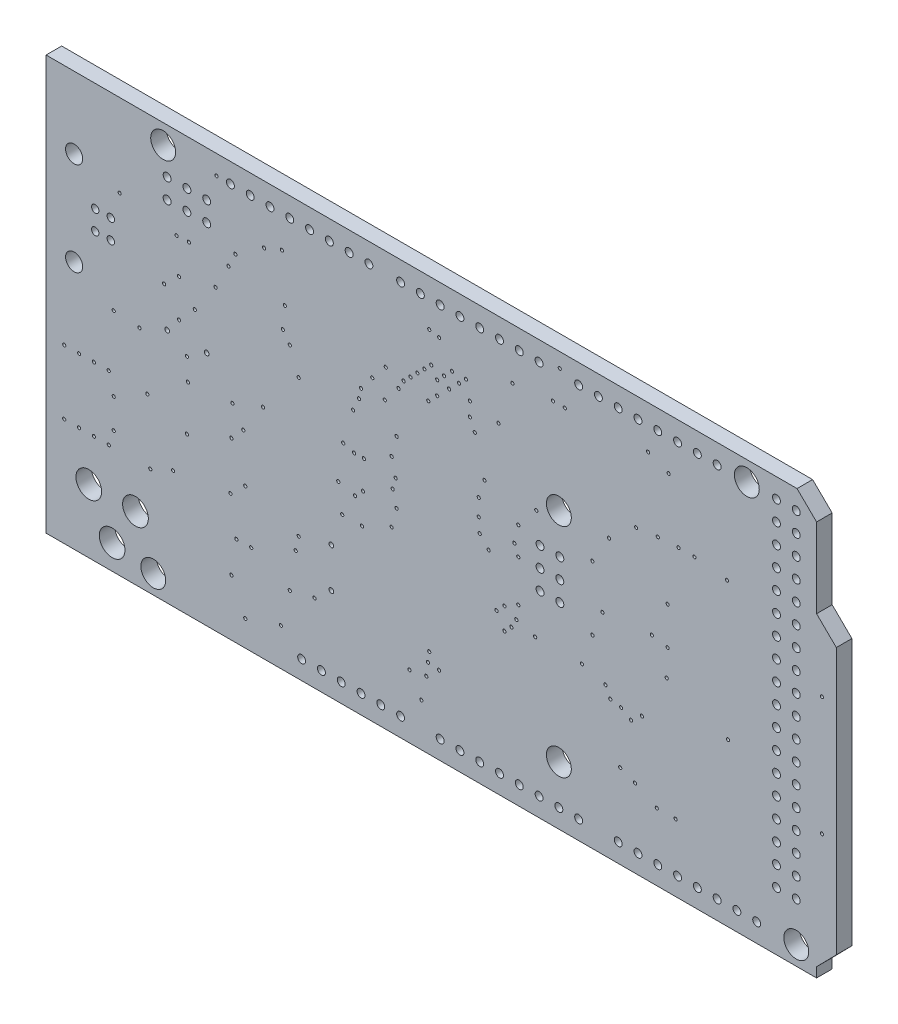
from build123d import *

# Parameters (mm, degrees)
SKETCH1_W           = 134.5210924
SKETCH1_H           = 72.181339
SKETCH1_R           = 1.5999968
SKETCH1_R_2         = 0.508
SKETCH1_R_3         = 0.3048
SKETCH1_R_4         = 1.651
SKETCH1_R_5         = 0.4750054
SKETCH1_R_6         = 1.0999978
SKETCH1_R_7         = 0.2032
BOSS_EXTRUDE1_DEPTH = 2
SKETCH2_W           = 162.13268737
SKETCH2_H           = 90.144306229
CUT_EXTRUDE1_DEPTH  = 10


with BuildPart() as part:
    # Sketch1 → Boss-Extrude1 (new body)
    with BuildSketch(Plane(origin=(0, 0, 0), x_dir=(-1, 0, 0), z_dir=(0, 0, -1))):
        with Locations((-40.0783056, -28.4573305)):
            Rectangle(SKETCH1_W, SKETCH1_H)
        with Locations((-81.88, -46.26)):
            Circle(SKETCH1_R, mode=Mode.SUBTRACT)
        with Locations((-0.6, 2)):
            Circle(SKETCH1_R, mode=Mode.SUBTRACT)
        with Locations((-75.53, 2)):
            Circle(SKETCH1_R, mode=Mode.SUBTRACT)
        with Locations((0.67, -46.26)):
            Circle(SKETCH1_R, mode=Mode.SUBTRACT)
        with Locations((-51.4, -13.24)):
            Circle(SKETCH1_R, mode=Mode.SUBTRACT)
        with Locations((-51.4, -41.18)):
            Circle(SKETCH1_R, mode=Mode.SUBTRACT)
        with Locations((-59.02, -46.26)):
            Circle(SKETCH1_R_2, mode=Mode.SUBTRACT)
        with Locations((-61.56, -46.26)):
            Circle(SKETCH1_R_2, mode=Mode.SUBTRACT)
        with Locations((-64.1, -46.26)):
            Circle(SKETCH1_R_2, mode=Mode.SUBTRACT)
        with Locations((-66.64, -46.26)):
            Circle(SKETCH1_R_2, mode=Mode.SUBTRACT)
        with Locations((-69.18, -46.26)):
            Circle(SKETCH1_R_2, mode=Mode.SUBTRACT)
        with Locations((-71.72, -46.26)):
            Circle(SKETCH1_R_2, mode=Mode.SUBTRACT)
        with Locations((-74.26, -46.26)):
            Circle(SKETCH1_R_2, mode=Mode.SUBTRACT)
        with Locations((-76.8, -46.26)):
            Circle(SKETCH1_R_2, mode=Mode.SUBTRACT)
        with Locations((-36.16, -46.26)):
            Circle(SKETCH1_R_2, mode=Mode.SUBTRACT)
        with Locations((-38.7, -46.26)):
            Circle(SKETCH1_R_2, mode=Mode.SUBTRACT)
        with Locations((-41.24, -46.26)):
            Circle(SKETCH1_R_2, mode=Mode.SUBTRACT)
        with Locations((-43.78, -46.26)):
            Circle(SKETCH1_R_2, mode=Mode.SUBTRACT)
        with Locations((-46.32, -46.26)):
            Circle(SKETCH1_R_2, mode=Mode.SUBTRACT)
        with Locations((-48.86, -46.26)):
            Circle(SKETCH1_R_2, mode=Mode.SUBTRACT)
        with Locations((-51.4, -46.26)):
            Circle(SKETCH1_R_2, mode=Mode.SUBTRACT)
        with Locations((-53.94, -46.26)):
            Circle(SKETCH1_R_2, mode=Mode.SUBTRACT)
        with Locations((-71.72, 2)):
            Circle(SKETCH1_R_2, mode=Mode.SUBTRACT)
        with Locations((-69.18, 2)):
            Circle(SKETCH1_R_2, mode=Mode.SUBTRACT)
        with Locations((-66.64, 2)):
            Circle(SKETCH1_R_2, mode=Mode.SUBTRACT)
        with Locations((-64.1, 2)):
            Circle(SKETCH1_R_2, mode=Mode.SUBTRACT)
        with Locations((-61.56, 2)):
            Circle(SKETCH1_R_2, mode=Mode.SUBTRACT)
        with Locations((-59.02, 2)):
            Circle(SKETCH1_R_2, mode=Mode.SUBTRACT)
        with Locations((-56.48, 2)):
            Circle(SKETCH1_R_2, mode=Mode.SUBTRACT)
        with Locations((-53.94, 2)):
            Circle(SKETCH1_R_2, mode=Mode.SUBTRACT)
        with Locations((-48.987, -18.32)):
            Circle(SKETCH1_R_2, mode=Mode.SUBTRACT)
        with Locations((-51.527, -18.32)):
            Circle(SKETCH1_R_2, mode=Mode.SUBTRACT)
        with Locations((-48.987, -20.86)):
            Circle(SKETCH1_R_2, mode=Mode.SUBTRACT)
        with Locations((-51.527, -20.86)):
            Circle(SKETCH1_R_2, mode=Mode.SUBTRACT)
        with Locations((-48.987, -23.4)):
            Circle(SKETCH1_R_2, mode=Mode.SUBTRACT)
        with Locations((-51.527, -23.4)):
            Circle(SKETCH1_R_2, mode=Mode.SUBTRACT)
        with Locations((-6.188, -1.302)):
            Circle(SKETCH1_R_2, mode=Mode.SUBTRACT)
        with Locations((-6.188, -3.842)):
            Circle(SKETCH1_R_2, mode=Mode.SUBTRACT)
        with Locations((-3.648, -1.302)):
            Circle(SKETCH1_R_2, mode=Mode.SUBTRACT)
        with Locations((-3.648, -3.842)):
            Circle(SKETCH1_R_2, mode=Mode.SUBTRACT)
        with Locations((-1.108, -1.302)):
            Circle(SKETCH1_R_2, mode=Mode.SUBTRACT)
        with Locations((-1.108, -3.842)):
            Circle(SKETCH1_R_2, mode=Mode.SUBTRACT)
        with Locations((-79.34, 2)):
            Circle(SKETCH1_R_2, mode=Mode.SUBTRACT)
        with Locations((-81.88, 2)):
            Circle(SKETCH1_R_2, mode=Mode.SUBTRACT)
        with Locations((-79.34, -41.18)):
            Circle(SKETCH1_R_2, mode=Mode.SUBTRACT)
        with Locations((-81.88, -41.18)):
            Circle(SKETCH1_R_2, mode=Mode.SUBTRACT)
        with Locations((-18.38, -46.26)):
            Circle(SKETCH1_R_2, mode=Mode.SUBTRACT)
        with Locations((-20.92, -46.26)):
            Circle(SKETCH1_R_2, mode=Mode.SUBTRACT)
        with Locations((-23.46, -46.26)):
            Circle(SKETCH1_R_2, mode=Mode.SUBTRACT)
        with Locations((-26, -46.26)):
            Circle(SKETCH1_R_2, mode=Mode.SUBTRACT)
        with Locations((-28.54, -46.26)):
            Circle(SKETCH1_R_2, mode=Mode.SUBTRACT)
        with Locations((-31.08, -46.26)):
            Circle(SKETCH1_R_2, mode=Mode.SUBTRACT)
        with Locations((-27.016, 2)):
            Circle(SKETCH1_R_2, mode=Mode.SUBTRACT)
        with Locations((-24.476, 2)):
            Circle(SKETCH1_R_2, mode=Mode.SUBTRACT)
        with Locations((-21.936, 2)):
            Circle(SKETCH1_R_2, mode=Mode.SUBTRACT)
        with Locations((-19.396, 2)):
            Circle(SKETCH1_R_2, mode=Mode.SUBTRACT)
        with Locations((-16.856, 2)):
            Circle(SKETCH1_R_2, mode=Mode.SUBTRACT)
        with Locations((-14.316, 2)):
            Circle(SKETCH1_R_2, mode=Mode.SUBTRACT)
        with Locations((-11.776, 2)):
            Circle(SKETCH1_R_2, mode=Mode.SUBTRACT)
        with Locations((-9.236, 2)):
            Circle(SKETCH1_R_2, mode=Mode.SUBTRACT)
        with Locations((-48.86, 2)):
            Circle(SKETCH1_R_2, mode=Mode.SUBTRACT)
        with Locations((-46.32, 2)):
            Circle(SKETCH1_R_2, mode=Mode.SUBTRACT)
        with Locations((-43.78, 2)):
            Circle(SKETCH1_R_2, mode=Mode.SUBTRACT)
        with Locations((-41.24, 2)):
            Circle(SKETCH1_R_2, mode=Mode.SUBTRACT)
        with Locations((-38.7, 2)):
            Circle(SKETCH1_R_2, mode=Mode.SUBTRACT)
        with Locations((-36.16, 2)):
            Circle(SKETCH1_R_2, mode=Mode.SUBTRACT)
        with Locations((-33.62, 2)):
            Circle(SKETCH1_R_2, mode=Mode.SUBTRACT)
        with Locations((-31.08, 2)):
            Circle(SKETCH1_R_2, mode=Mode.SUBTRACT)
        with Locations((-6.188, -18.32)):
            Circle(SKETCH1_R_3, mode=Mode.SUBTRACT)
        with Locations((-1.108, -18.32)):
            Circle(SKETCH1_R_3, mode=Mode.SUBTRACT)
        with Locations((-22.19, -31.655)):
            Circle(SKETCH1_R_3, mode=Mode.SUBTRACT)
        with Locations((-22.19, -36.735)):
            Circle(SKETCH1_R_3, mode=Mode.SUBTRACT)
        with Locations((5.9532, -45.498)):
            Circle(SKETCH1_R_4, mode=Mode.SUBTRACT)
        with Locations((2.956, -40.4942)):
            Circle(SKETCH1_R_4, mode=Mode.SUBTRACT)
        with Locations((8.9504, -40.4942)):
            Circle(SKETCH1_R_4, mode=Mode.SUBTRACT)
        with Locations((6.1200018, -11.9500102)):
            Circle(SKETCH1_R_5, mode=Mode.SUBTRACT)
        with Locations((6.1200018, -9.4499898)):
            Circle(SKETCH1_R_5, mode=Mode.SUBTRACT)
        with Locations((8.1199978, -9.4499898)):
            Circle(SKETCH1_R_5, mode=Mode.SUBTRACT)
        with Locations((8.1199978, -11.9500102)):
            Circle(SKETCH1_R_5, mode=Mode.SUBTRACT)
        with Locations((10.83, -4.700012)):
            Circle(SKETCH1_R_6, mode=Mode.SUBTRACT)
        with Locations((10.83, -16.699988)):
            Circle(SKETCH1_R_6, mode=Mode.SUBTRACT)
        with Locations((-81.88, -18.32)):
            Circle(SKETCH1_R_2, mode=Mode.SUBTRACT)
        with Locations((-79.34, -18.32)):
            Circle(SKETCH1_R_2, mode=Mode.SUBTRACT)
        with Locations((-81.88, -15.78)):
            Circle(SKETCH1_R_2, mode=Mode.SUBTRACT)
        with Locations((-79.34, -15.78)):
            Circle(SKETCH1_R_2, mode=Mode.SUBTRACT)
        with Locations((-81.88, -13.24)):
            Circle(SKETCH1_R_2, mode=Mode.SUBTRACT)
        with Locations((-79.34, -13.24)):
            Circle(SKETCH1_R_2, mode=Mode.SUBTRACT)
        with Locations((-81.88, -10.7)):
            Circle(SKETCH1_R_2, mode=Mode.SUBTRACT)
        with Locations((-79.34, -10.7)):
            Circle(SKETCH1_R_2, mode=Mode.SUBTRACT)
        with Locations((-81.88, -8.16)):
            Circle(SKETCH1_R_2, mode=Mode.SUBTRACT)
        with Locations((-79.34, -8.16)):
            Circle(SKETCH1_R_2, mode=Mode.SUBTRACT)
        with Locations((-81.88, -5.62)):
            Circle(SKETCH1_R_2, mode=Mode.SUBTRACT)
        with Locations((-79.34, -5.62)):
            Circle(SKETCH1_R_2, mode=Mode.SUBTRACT)
        with Locations((-81.88, -3.08)):
            Circle(SKETCH1_R_2, mode=Mode.SUBTRACT)
        with Locations((-79.34, -3.08)):
            Circle(SKETCH1_R_2, mode=Mode.SUBTRACT)
        with Locations((-81.88, -0.54)):
            Circle(SKETCH1_R_2, mode=Mode.SUBTRACT)
        with Locations((-79.34, -0.54)):
            Circle(SKETCH1_R_2, mode=Mode.SUBTRACT)
        with Locations((-81.88, -38.64)):
            Circle(SKETCH1_R_2, mode=Mode.SUBTRACT)
        with Locations((-79.34, -38.64)):
            Circle(SKETCH1_R_2, mode=Mode.SUBTRACT)
        with Locations((-81.88, -36.1)):
            Circle(SKETCH1_R_2, mode=Mode.SUBTRACT)
        with Locations((-79.34, -36.1)):
            Circle(SKETCH1_R_2, mode=Mode.SUBTRACT)
        with Locations((-81.88, -33.56)):
            Circle(SKETCH1_R_2, mode=Mode.SUBTRACT)
        with Locations((-79.34, -33.56)):
            Circle(SKETCH1_R_2, mode=Mode.SUBTRACT)
        with Locations((-81.88, -31.02)):
            Circle(SKETCH1_R_2, mode=Mode.SUBTRACT)
        with Locations((-79.34, -31.02)):
            Circle(SKETCH1_R_2, mode=Mode.SUBTRACT)
        with Locations((-81.88, -28.48)):
            Circle(SKETCH1_R_2, mode=Mode.SUBTRACT)
        with Locations((-79.34, -28.48)):
            Circle(SKETCH1_R_2, mode=Mode.SUBTRACT)
        with Locations((-81.88, -25.94)):
            Circle(SKETCH1_R_2, mode=Mode.SUBTRACT)
        with Locations((-79.34, -25.94)):
            Circle(SKETCH1_R_2, mode=Mode.SUBTRACT)
        with Locations((-81.88, -23.4)):
            Circle(SKETCH1_R_2, mode=Mode.SUBTRACT)
        with Locations((-79.34, -23.4)):
            Circle(SKETCH1_R_2, mode=Mode.SUBTRACT)
        with Locations((-81.88, -20.86)):
            Circle(SKETCH1_R_2, mode=Mode.SUBTRACT)
        with Locations((-79.34, -20.86)):
            Circle(SKETCH1_R_2, mode=Mode.SUBTRACT)
        with Locations((-20.031, -38.64)):
            Circle(SKETCH1_R_7, mode=Mode.SUBTRACT)
        with Locations((-9.363, -26.194)):
            Circle(SKETCH1_R_7, mode=Mode.SUBTRACT)
        with Locations((-15.713, -43.847)):
            Circle(SKETCH1_R_7, mode=Mode.SUBTRACT)
        with Locations((-17.618, -34.576)):
            Circle(SKETCH1_R_7, mode=Mode.SUBTRACT)
        with Locations((-68.799, -9.684)):
            Circle(SKETCH1_R_7, mode=Mode.SUBTRACT)
        with Locations((-41.8496, -14.637)):
            Circle(SKETCH1_R_7, mode=Mode.SUBTRACT)
        with Locations((-48.5044, -14.6624)):
            Circle(SKETCH1_R_7, mode=Mode.SUBTRACT)
        with Locations((-42.383, -22.13)):
            Circle(SKETCH1_R_7, mode=Mode.SUBTRACT)
        with Locations((-29.937, -17.939)):
            Circle(SKETCH1_R_7, mode=Mode.SUBTRACT)
        with Locations((-29.048, -12.097)):
            Circle(SKETCH1_R_7, mode=Mode.SUBTRACT)
        with Locations((8.29, -26.575)):
            Circle(SKETCH1_R_7, mode=Mode.SUBTRACT)
        with Locations((5.75, -19.59)):
            Circle(SKETCH1_R_7, mode=Mode.SUBTRACT)
        with Locations((10.195, -26.575)):
            Circle(SKETCH1_R_7, mode=Mode.SUBTRACT)
        with Locations((6.385, -26.575)):
            Circle(SKETCH1_R_7, mode=Mode.SUBTRACT)
        with Locations((12.1, -26.575)):
            Circle(SKETCH1_R_7, mode=Mode.SUBTRACT)
        with Locations((5.75, -29.115)):
            Circle(SKETCH1_R_7, mode=Mode.SUBTRACT)
        with Locations((12.1, -34.83)):
            Circle(SKETCH1_R_7, mode=Mode.SUBTRACT)
        with Locations((8.29, -34.83)):
            Circle(SKETCH1_R_7, mode=Mode.SUBTRACT)
        with Locations((10.195, -34.83)):
            Circle(SKETCH1_R_7, mode=Mode.SUBTRACT)
        with Locations((5.75, -32.925)):
            Circle(SKETCH1_R_7, mode=Mode.SUBTRACT)
        with Locations((6.385, -34.83)):
            Circle(SKETCH1_R_7, mode=Mode.SUBTRACT)
        with Locations((-0.727, -13.367)):
            Circle(SKETCH1_R_7, mode=Mode.SUBTRACT)
        with Locations((-4.664, -14.256)):
            Circle(SKETCH1_R_7, mode=Mode.SUBTRACT)
        with Locations((-13.427, -20.733)):
            Circle(SKETCH1_R_7, mode=Mode.SUBTRACT)
        with Locations((-8.982, -7.271)):
            Circle(SKETCH1_R_7, mode=Mode.SUBTRACT)
        with Locations((-9.236, -32.417)):
            Circle(SKETCH1_R_7, mode=Mode.SUBTRACT)
        with Locations((-30.826, -9.938)):
            Circle(SKETCH1_R_7, mode=Mode.SUBTRACT)
        with Locations((-31.461, -8.795)):
            Circle(SKETCH1_R_7, mode=Mode.SUBTRACT)
        with Locations((-32.35, -7.906)):
            Circle(SKETCH1_R_7, mode=Mode.SUBTRACT)
        with Locations((-33.239, -7.017)):
            Circle(SKETCH1_R_7, mode=Mode.SUBTRACT)
        with Locations((-34.128, -6.128)):
            Circle(SKETCH1_R_7, mode=Mode.SUBTRACT)
        with Locations((-35.017, -5.239)):
            Circle(SKETCH1_R_7, mode=Mode.SUBTRACT)
        with Locations((-34.636, -9.43)):
            Circle(SKETCH1_R_7, mode=Mode.SUBTRACT)
        with Locations((-35.779, -6.509)):
            Circle(SKETCH1_R_7, mode=Mode.SUBTRACT)
        with Locations((-35.779, -8.287)):
            Circle(SKETCH1_R_7, mode=Mode.SUBTRACT)
        with Locations((-36.668, -5.62)):
            Circle(SKETCH1_R_7, mode=Mode.SUBTRACT)
        with Locations((-37.303, -6.763)):
            Circle(SKETCH1_R_7, mode=Mode.SUBTRACT)
        with Locations((-37.684, -4.604)):
            Circle(SKETCH1_R_7, mode=Mode.SUBTRACT)
        with Locations((-38.573, -5.493)):
            Circle(SKETCH1_R_7, mode=Mode.SUBTRACT)
        with Locations((-39.462, -4.604)):
            Circle(SKETCH1_R_7, mode=Mode.SUBTRACT)
        with Locations((-39.97, -6.763)):
            Circle(SKETCH1_R_7, mode=Mode.SUBTRACT)
        with Locations((-39.97, -8.541)):
            Circle(SKETCH1_R_7, mode=Mode.SUBTRACT)
        with Locations((-27.4478, -10.446)):
            Circle(SKETCH1_R_7, mode=Mode.SUBTRACT)
        with Locations((-13.554, -2.953)):
            Circle(SKETCH1_R_7, mode=Mode.SUBTRACT)
        with Locations((-11.141, -30.639)):
            Circle(SKETCH1_R_7, mode=Mode.SUBTRACT)
        with Locations((-7.331, -10.446)):
            Circle(SKETCH1_R_7, mode=Mode.SUBTRACT)
        with Locations((-3.775, -22.765)):
            Circle(SKETCH1_R_7, mode=Mode.SUBTRACT)
        with Locations((-41.24, -20.86)):
            Circle(SKETCH1_R_7, mode=Mode.SUBTRACT)
        with Locations((-46.193, -17.431)):
            Circle(SKETCH1_R_7, mode=Mode.SUBTRACT)
        with Locations((-54.359989, -28.7999892)):
            Circle(SKETCH1_R_7, mode=Mode.SUBTRACT)
        with Locations((-23.587, -27.591)):
            Circle(SKETCH1_R_7, mode=Mode.SUBTRACT)
        with Locations((-30.445, -20.098)):
            Circle(SKETCH1_R_7, mode=Mode.SUBTRACT)
        with Locations((-30.572, -15.399)):
            Circle(SKETCH1_R_7, mode=Mode.SUBTRACT)
        with Locations((-40.605, -9.938)):
            Circle(SKETCH1_R_7, mode=Mode.SUBTRACT)
        with Locations((-17.999, -15.145)):
            Circle(SKETCH1_R_7, mode=Mode.SUBTRACT)
        with Locations((-23.714, -19.573998)):
            Circle(SKETCH1_R_7, mode=Mode.SUBTRACT)
        with Locations((-72.99, -10.192)):
            Circle(SKETCH1_R_7, mode=Mode.SUBTRACT)
        with Locations((-73.117, -27.845)):
            Circle(SKETCH1_R_7, mode=Mode.SUBTRACT)
        with Locations((-57.8516, -13.0876)):
            Circle(SKETCH1_R_7, mode=Mode.SUBTRACT)
        with Locations((-9.998, -37.116)):
            Circle(SKETCH1_R_7, mode=Mode.SUBTRACT)
        with Locations((1.051, -34.83)):
            Circle(SKETCH1_R_7, mode=Mode.SUBTRACT)
        with Locations((-17.999, -32.798)):
            Circle(SKETCH1_R_7, mode=Mode.SUBTRACT)
        with Locations((-26.127, -27.591)):
            Circle(SKETCH1_R_7, mode=Mode.SUBTRACT)
        with Locations((-2.632, -11.589)):
            Circle(SKETCH1_R_7, mode=Mode.SUBTRACT)
        with Locations((-3.902, -7.144)):
            Circle(SKETCH1_R_7, mode=Mode.SUBTRACT)
        with Locations((-10.887, -24.543)):
            Circle(SKETCH1_R_7, mode=Mode.SUBTRACT)
        with Locations((-43.653, -7.398)):
            Circle(SKETCH1_R_7, mode=Mode.SUBTRACT)
        with Locations((-62.8554, -0.9972)):
            Circle(SKETCH1_R_7, mode=Mode.SUBTRACT)
        with Locations((-29.175, -8.414)):
            Circle(SKETCH1_R_7, mode=Mode.SUBTRACT)
        with Locations((-30.064, -21.495)):
            Circle(SKETCH1_R_7, mode=Mode.SUBTRACT)
        with Locations((-33.747, -43.133006)):
            Circle(SKETCH1_R_7, mode=Mode.SUBTRACT)
        with Locations((-11.141, -45.371)):
            Circle(SKETCH1_R_7, mode=Mode.SUBTRACT)
        with Locations((1.432, -26.702)):
            Circle(SKETCH1_R_7, mode=Mode.SUBTRACT)
        with Locations((-9.49, -22.257)):
            Circle(SKETCH1_R_7, mode=Mode.SUBTRACT)
        with Locations((-9.871, -5.493)):
            Circle(SKETCH1_R_7, mode=Mode.SUBTRACT)
        with Locations((-46.193, -20.987)):
            Circle(SKETCH1_R_7, mode=Mode.SUBTRACT)
        with Locations((-43.399, -28.353)):
            Circle(SKETCH1_R_7, mode=Mode.SUBTRACT)
        with Locations((2.448, -19.844)):
            Circle(SKETCH1_R_7, mode=Mode.SUBTRACT)
        with Locations((-23.079, -24.162)):
            Circle(SKETCH1_R_7, mode=Mode.SUBTRACT)
        with Locations((-63.338, -21.114)):
            Circle(SKETCH1_R_7, mode=Mode.SUBTRACT)
        with Locations((-62.068, -30.757999)):
            Circle(SKETCH1_R_7, mode=Mode.SUBTRACT)
        with Locations((-85.165998, -17.05)):
            Circle(SKETCH1_R_7, mode=Mode.SUBTRACT)
        with Locations((-65.243, -24.924)):
            Circle(SKETCH1_R_7, mode=Mode.SUBTRACT)
        with Locations((-55.718, -24.924)):
            Circle(SKETCH1_R_7, mode=Mode.SUBTRACT)
        with Locations((-56.988, -21.749)):
            Circle(SKETCH1_R_7, mode=Mode.SUBTRACT)
        with Locations((-3.648, -19.971)):
            Circle(SKETCH1_R_7, mode=Mode.SUBTRACT)
        with Locations((-55.7015916, -16.7026042)):
            Circle(SKETCH1_R_7, mode=Mode.SUBTRACT)
        with Locations((-48.360001, -28.7999892)):
            Circle(SKETCH1_R_7, mode=Mode.SUBTRACT)
        with Locations((-2.632, -16.415)):
            Circle(SKETCH1_R_7, mode=Mode.SUBTRACT)
        with Locations((-85.165998, -32.29)):
            Circle(SKETCH1_R_7, mode=Mode.SUBTRACT)
        with Locations((-51.510998, 2.635)):
            Circle(SKETCH1_R_7, mode=Mode.SUBTRACT)
        with Locations((-7.441998, 2)):
            Circle(SKETCH1_R_7, mode=Mode.SUBTRACT)
        with Locations((-3.648, -28.607)):
            Circle(SKETCH1_R_7, mode=Mode.SUBTRACT)
        with Locations((-61.322002, -10.175998)):
            Circle(SKETCH1_R_7, mode=Mode.SUBTRACT)
        with Locations((-65.497, -2.064)):
            Circle(SKETCH1_R_7, mode=Mode.SUBTRACT)
        with Locations((-45.431, -2.064)):
            Circle(SKETCH1_R_7, mode=Mode.SUBTRACT)
        with Locations((-15.84, -2.064)):
            Circle(SKETCH1_R_7, mode=Mode.SUBTRACT)
        with Locations((-30.572, -23.4)):
            Circle(SKETCH1_R_7, mode=Mode.SUBTRACT)
        with Locations((-34.763, -37.243)):
            Circle(SKETCH1_R_7, mode=Mode.SUBTRACT)
        with Locations((-59.274, -37.878)):
            Circle(SKETCH1_R_7, mode=Mode.SUBTRACT)
        with Locations((-26.254, -23.654)):
            Circle(SKETCH1_R_7, mode=Mode.SUBTRACT)
        with Locations((-34.5900006, -38.513)):
            Circle(SKETCH1_R_7, mode=Mode.SUBTRACT)
        with Locations((-25.238, -24.67)):
            Circle(SKETCH1_R_7, mode=Mode.SUBTRACT)
        with Locations((-36.033, -38.6750012)):
            Circle(SKETCH1_R_7, mode=Mode.SUBTRACT)
        with Locations((-61.179, -38.64)):
            Circle(SKETCH1_R_7, mode=Mode.SUBTRACT)
        with Locations((-29.937, -25.813)):
            Circle(SKETCH1_R_7, mode=Mode.SUBTRACT)
        with Locations((-34.382, -40.164)):
            Circle(SKETCH1_R_7, mode=Mode.SUBTRACT)
        with Locations((-66.386, -40.037)):
            Circle(SKETCH1_R_7, mode=Mode.SUBTRACT)
        with Locations((-16.221, -8.033)):
            Circle(SKETCH1_R_7, mode=Mode.SUBTRACT)
        with Locations((-15.967, -10.827)):
            Circle(SKETCH1_R_7, mode=Mode.SUBTRACT)
        with Locations((-26, -12.351)):
            Circle(SKETCH1_R_7, mode=Mode.SUBTRACT)
        with Locations((-25.746, -13.621)):
            Circle(SKETCH1_R_7, mode=Mode.SUBTRACT)
        with Locations((-24.984, -15.272)):
            Circle(SKETCH1_R_7, mode=Mode.SUBTRACT)
        with Locations((-16.856, -12.097)):
            Circle(SKETCH1_R_7, mode=Mode.SUBTRACT)
        with Locations((-34.763, -1.429)):
            Circle(SKETCH1_R_7, mode=Mode.SUBTRACT)
        with Locations((-44.415, -27.337)):
            Circle(SKETCH1_R_7, mode=Mode.SUBTRACT)
        with Locations((-44.415, -30.131)):
            Circle(SKETCH1_R_7, mode=Mode.SUBTRACT)
        with Locations((-46.193, -26.321)):
            Circle(SKETCH1_R_7, mode=Mode.SUBTRACT)
        with Locations((-45.304, -29.242)):
            Circle(SKETCH1_R_7, mode=Mode.SUBTRACT)
        with Locations((-45.939, -28.099)):
            Circle(SKETCH1_R_7, mode=Mode.SUBTRACT)
        with Locations((-45.685, -19.717)):
            Circle(SKETCH1_R_7, mode=Mode.SUBTRACT)
        with Locations((-36.033, -1.683)):
            Circle(SKETCH1_R_7, mode=Mode.SUBTRACT)
        with Locations((-11.903, -37.116)):
            Circle(SKETCH1_R_7, mode=Mode.SUBTRACT)
        with Locations((-63.973, -40.037)):
            Circle(SKETCH1_R_7, mode=Mode.SUBTRACT)
        with Locations((-32.214999, -40.536999)):
            Circle(SKETCH1_R_7, mode=Mode.SUBTRACT)
        with Locations((-16.856, -39.402)):
            Circle(SKETCH1_R_7, mode=Mode.SUBTRACT)
        with Locations((-65.37, -21.495)):
            Circle(SKETCH1_R_7, mode=Mode.SUBTRACT)
        with Locations((-65.37, -16.669)):
            Circle(SKETCH1_R_7, mode=Mode.SUBTRACT)
        with Locations((-2.3145, -7.2075)):
            Circle(SKETCH1_R_7, mode=Mode.SUBTRACT)
        with Locations((-1.87, -33.56)):
            Circle(SKETCH1_R_7, mode=Mode.SUBTRACT)
        with Locations((-58.004, -30.893)):
            Circle(SKETCH1_R_7, mode=Mode.SUBTRACT)
        with Locations((-26.381, -19.971)):
            Circle(SKETCH1_R_7, mode=Mode.SUBTRACT)
        with Locations((-52.162, -1.429)):
            Circle(SKETCH1_R_7, mode=Mode.SUBTRACT)
        with Locations((-41.113, -19.082)):
            Circle(SKETCH1_R_7, mode=Mode.SUBTRACT)
        with Locations((-66.767, -9.684)):
            Circle(SKETCH1_R_7, mode=Mode.SUBTRACT)
        with Locations((-60.671, -31.909)):
            Circle(SKETCH1_R_7, mode=Mode.SUBTRACT)
        with Locations((-59.401, -31.147)):
            Circle(SKETCH1_R_7, mode=Mode.SUBTRACT)
        with Locations((-64.1, -9.811)):
            Circle(SKETCH1_R_7, mode=Mode.SUBTRACT)
        with Locations((-57.369, -29.623)):
            Circle(SKETCH1_R_7, mode=Mode.SUBTRACT)
        with Locations((-25.111, -19.971)):
            Circle(SKETCH1_R_7, mode=Mode.SUBTRACT)
        with Locations((-50.638, -1.429)):
            Circle(SKETCH1_R_7, mode=Mode.SUBTRACT)
        with Locations((-41.113, -16.923)):
            Circle(SKETCH1_R_7, mode=Mode.SUBTRACT)
        with Locations((4.988, -6.128)):
            Circle(SKETCH1_R_7, mode=Mode.SUBTRACT)
        with Locations((-9.363, -41.434)):
            Circle(SKETCH1_R_7, mode=Mode.SUBTRACT)
    extrude(amount=-BOSS_EXTRUDE1_DEPTH)

    # Sketch2 → Cut-Extrude1 (cut)
    with BuildSketch(Plane.XY.offset(2)):
        with Locations((36.77751907, -24.452633364)):
            Rectangle(SKETCH2_W, SKETCH2_H)
        Polygon((-14.431067296, 4.498567891), (81.978998526, 4.498567891), (84.486391552, 2.039022194), (84.486391552, -8.164329625), (87.023949949, -10.653465062), (87.023949949, -44.819469807), (84.486391552, -47.40639317), (84.486391552, -48.666051309), (-14.431067296, -48.666051309), align=None, mode=Mode.SUBTRACT)
    extrude(amount=-CUT_EXTRUDE1_DEPTH, mode=Mode.SUBTRACT)


solid = part.part
